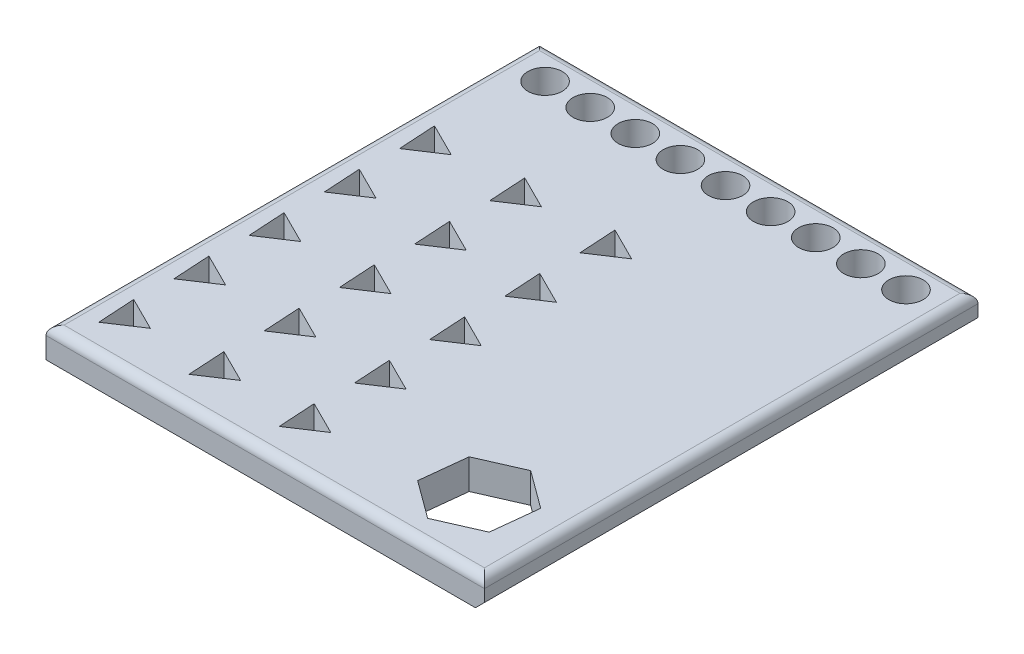
from build123d import *

# Parameters (mm, degrees)
SKETCH1_W            = 145.774647888
SKETCH1_H            = 164.084507042
BOSS_EXTRUDE1_DEPTH  = 10
FILLET1_R            = 3
SKETCH2_R            = 5.718299624
CUT_EXTRUDE1_DEPTH   = 10
LPATTERN1_COUNT      = 9
LPATTERN1_PITCH      = 15
CUT_EXTRUDE2_DEPTH   = 10
LPATTERN2_COUNT      = 5
LPATTERN2_PITCH      = 25
LPATTERN2_COUNT_DIR2 = 3
LPATTERN2_PITCH_DIR2 = 30
CHAMFER1_SIZE        = 3


with BuildPart() as part:
    # Sketch1 → Boss-Extrude1 (new body)
    with BuildSketch(Plane(origin=(0, 0, 0), x_dir=(1, 0, 0), z_dir=(0, 1, 0))):
        Rectangle(SKETCH1_W, SKETCH1_H)
        Polygon((60.399278767, -67.985661607), (62.095878149, -52.558568526), (49.583923326, -43.375723821), (35.375369121, -49.619972196), (33.678769738, -65.047065276), (46.190724561, -74.229909982), align=None, mode=Mode.SUBTRACT)
    extrude(amount=BOSS_EXTRUDE1_DEPTH)

    # Fillet1
    fillet1_edges = [part.edges().sort_by_distance(p)[0] for p in [
        (-72.887323944, 10, 0),
        (0, 10, 82.042253521),
        (72.887323944, 10, 0),
        (0, 10, -82.042253521),
    ]]
    fillet(fillet1_edges, radius=FILLET1_R)

    # Sketch2 → Cut-Extrude1 (cut)
    with BuildSketch(Plane(origin=(0, 10, 0), x_dir=(1, 0, 0), z_dir=(0, 1, 0))):
        with Locations((-60.091318796, 71.08363321)):
            Circle(SKETCH2_R)
    cut_extrude1 = extrude(amount=-CUT_EXTRUDE1_DEPTH, mode=Mode.SUBTRACT)

    # LPattern1: Cut-Extrude1 ×9
    with Locations(*[(i * LPATTERN1_PITCH, 0, 0) for i in range(1, LPATTERN1_COUNT)]):
        add(cut_extrude1, mode=Mode.SUBTRACT)

    # Sketch3 → Cut-Extrude2 (cut)
    with BuildSketch(Plane(origin=(0, 10, 0), x_dir=(1, 0, 0), z_dir=(0, 1, 0))):
        Polygon((-64.940245829, 27.550407321), (-54.604744837, 34.374463584), (-65.682301413, 39.913241872), align=None)
    cut_extrude2 = extrude(amount=-CUT_EXTRUDE2_DEPTH, mode=Mode.SUBTRACT)

    # LPattern2: Cut-Extrude2 5 × 3
    with Locations(*[(j * LPATTERN2_PITCH_DIR2, 0, i * LPATTERN2_PITCH) for i in range(LPATTERN2_COUNT) for j in range(LPATTERN2_COUNT_DIR2) if (i, j) != (0, 0)]):
        add(cut_extrude2, mode=Mode.SUBTRACT)

    # Chamfer1
    chamfer1_edges = [part.edges().sort_by_distance(p)[0] for p in [
        (0, 0, -82.042253521),
        (72.887323944, 0, 0),
    ]]
    chamfer(chamfer1_edges, length=CHAMFER1_SIZE)


solid = part.part
